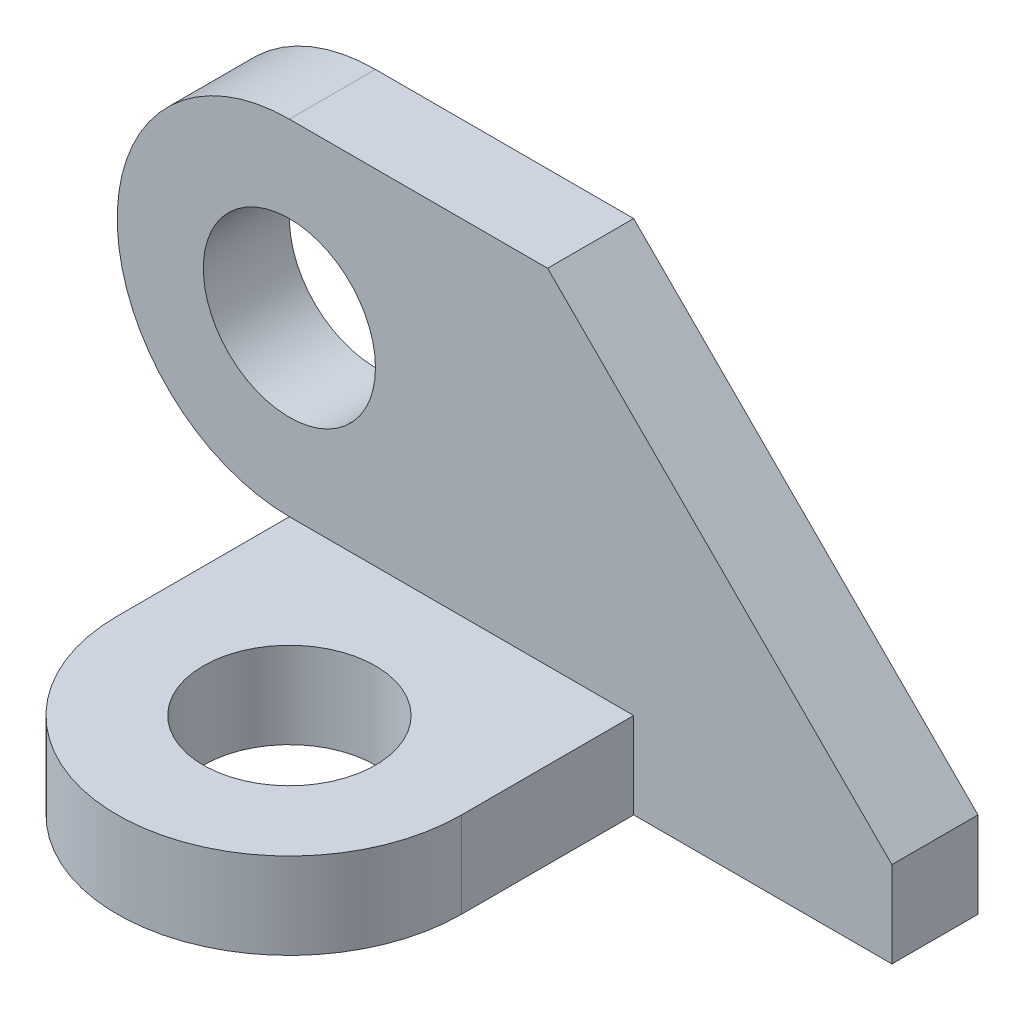
from build123d import *

# Parameters (mm, degrees)
SKETCH_1_R      = 5
EXTRUDE_1_DEPTH = 5
EXTRUDE_START   = -15
SKETCH_2_R      = 5
EXTRUDE_2_DEPTH = 5
SCALE_1_SCALE   = 0.2


with BuildPart() as part:
    # 草圖1 → 填料-伸長1 (new body)
    with BuildSketch(Plane.XY):
        with BuildLine():
            Line((0, 10), (15, 10))
            Line((15, 10), (35, -10))
            Line((35, -10), (35, -15))
            Line((35, -15), (0, -15))
            Line((0, -15), (0, -10))
            ThreePointArc((0, -10), (-10, 0), (0, 10))
        make_face()
        Circle(SKETCH_1_R, mode=Mode.SUBTRACT)
    extrude(amount=EXTRUDE_1_DEPTH)

    # 草圖2 → 填料-伸長2 (add)
    with BuildSketch(Plane(origin=(0, 0, 0), x_dir=(1, 0, 0), z_dir=(0, 1, 0)).offset(EXTRUDE_START)):
        with BuildLine():
            Line((0, -15), (0, -5))
            Line((0, -5), (20, -5))
            Line((20, -5), (20, -15))
            ThreePointArc((20, -15), (10, -25), (0, -15))
        make_face()
        with Locations((10, -15)):
            Circle(SKETCH_2_R, mode=Mode.SUBTRACT)
    extrude(amount=EXTRUDE_2_DEPTH)


with BuildPart() as part_1:
    # 縮放比例1: scaled about (11.398892544, -6.138978205, 5.550553728)
    add(part.part.scale(SCALE_1_SCALE).moved(Location((9.119114035, -4.911182564, 4.440442982))))


solid = part_1.part
